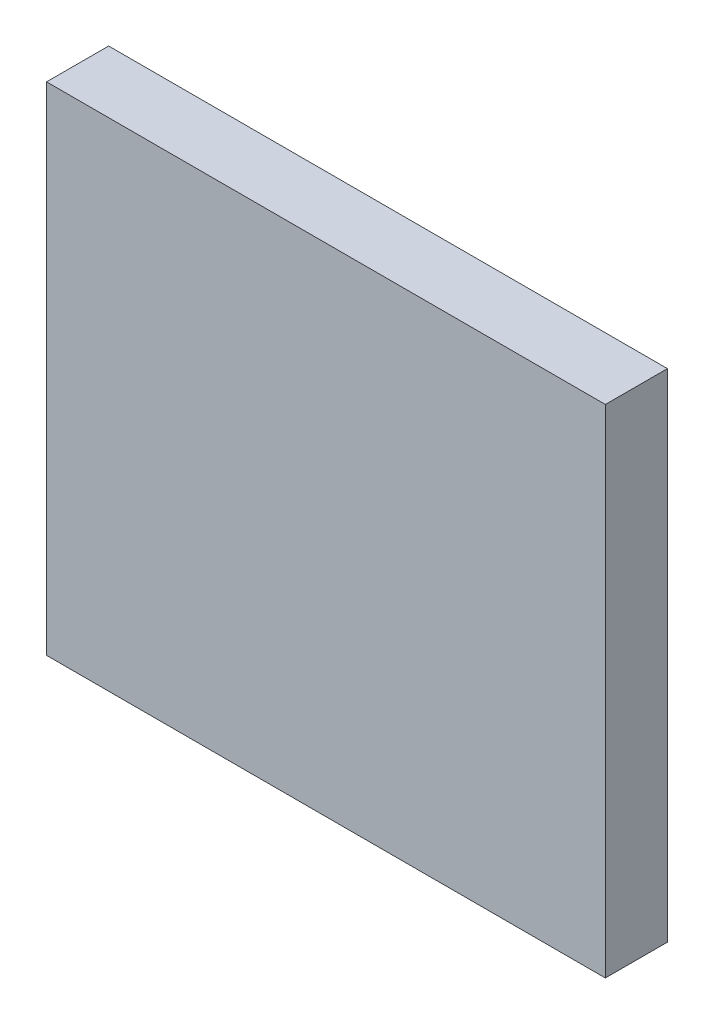
from build123d import *

# Parameters (mm, degrees)
ESQUISSE1_W        = 270
ESQUISSE1_H        = 240
BOSS_EXTRU_1_DEPTH = 30


with BuildPart() as part:
    # Esquisse1 → Boss.-Extru.1 (new body)
    with BuildSketch(Plane.XY):
        Rectangle(ESQUISSE1_W, ESQUISSE1_H)
    extrude(amount=BOSS_EXTRU_1_DEPTH)


solid = part.part
